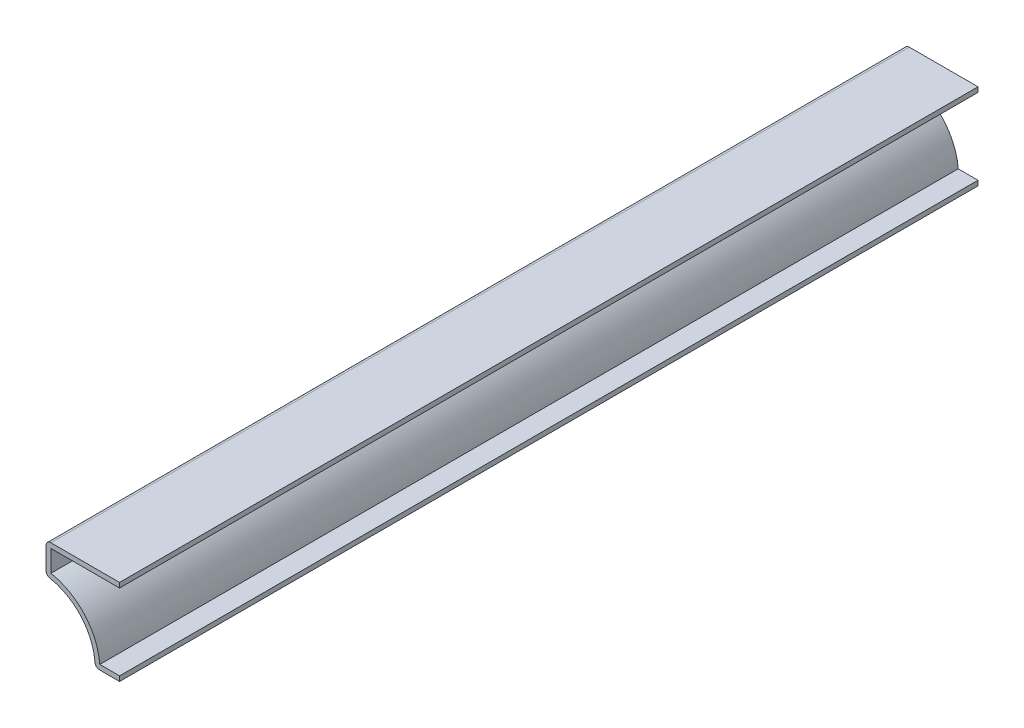
from build123d import *

# Parameters (mm, degrees)
EXTRUDE_THIN1_DEPTH = 222.25
FILLET1_R           = 1.27


with BuildPart() as part:
    # Sketch1 → Extrude-Thin1 (new body)
    with BuildSketch(Plane.XY):
        with BuildLine():
            Line((0, 0), (-6.35, 0))
            ThreePointArc((-6.35, 0), (-9.958615648, 9.580536091), (-19.05, 14.2875))
            Line((-19.05, 14.2875), (-19.05, 22.225))
            Line((-19.05, 22.225), (0, 22.225))
            Line((0, 22.225), (0, 20.955))
            Line((0, 20.955), (-17.78, 20.955))
            Line((-17.78, 20.955), (-17.78, 15.381314))
            ThreePointArc((-17.78, 15.381314), (-9.055144579, 10.475506123), (-5.12465987, 1.27))
            Line((-5.12465987, 1.27), (0, 1.27))
            Line((0, 1.27), (0, 0))
        make_face()
    extrude(amount=-EXTRUDE_THIN1_DEPTH)

    # Fillet1
    fillet1_edges = [part.edges().sort_by_distance(p)[0] for p in [
        (-6.35, 0, -111.125),
        (-19.05, 14.2875, -111.125),
        (-19.05, 22.225, -111.125),
    ]]
    fillet(fillet1_edges, radius=FILLET1_R)


solid = part.part
